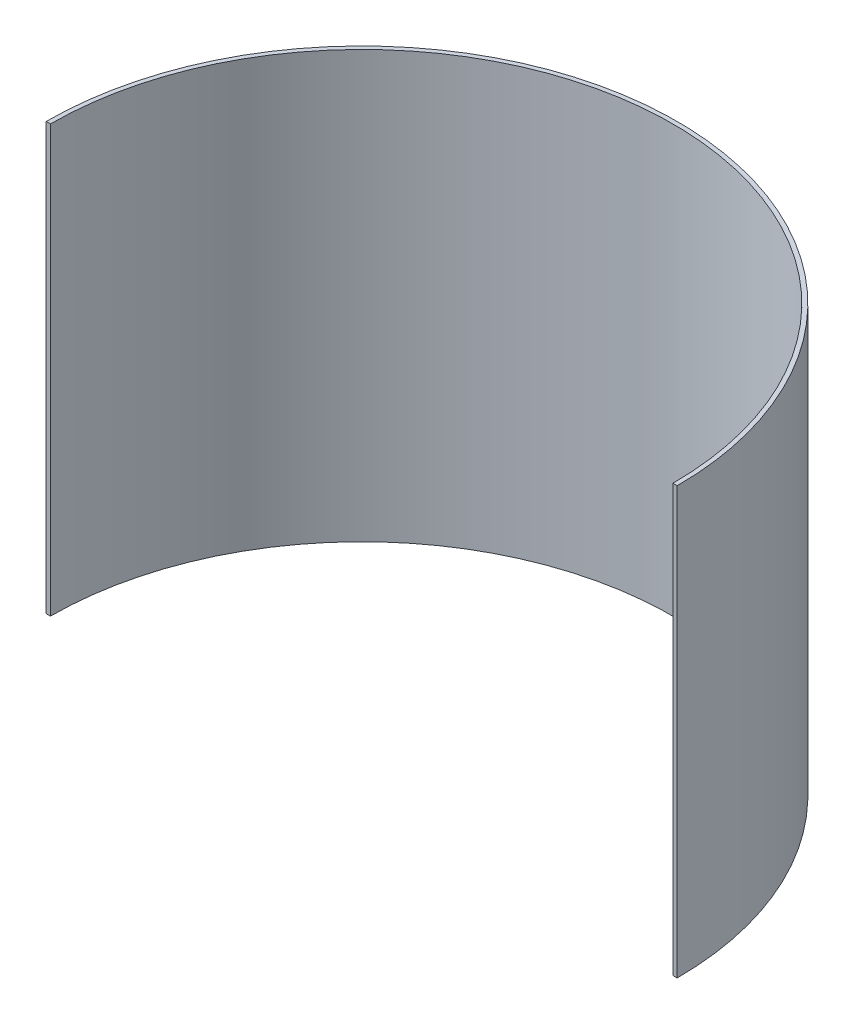
from build123d import *

# Parameters (mm, degrees)
SKETCH1_R           = 37
SKETCH1_R_2         = 36.5
BOSS_EXTRUDE1_DEPTH = 50
CUT_EXTRUDE2_DEPTH  = 51


with BuildPart() as part:
    # Sketch1 → Boss-Extrude1 (new body)
    with BuildSketch(Plane(origin=(0, 0, 0), x_dir=(1, 0, 0), z_dir=(0, 1, 0))):
        Circle(SKETCH1_R)
        Circle(SKETCH1_R_2, mode=Mode.SUBTRACT)
    extrude(amount=BOSS_EXTRUDE1_DEPTH)

    # Sketch2 → Cut-Extrude2 (cut, through all)
    with BuildSketch(Plane(origin=(0, 0, 0), x_dir=(1, 0, 0), z_dir=(0, 1, 0))):
        with BuildLine():
            Line((37, 0), (-37, 0))
            ThreePointArc((-37, 0), (0, -37), (37, 0))
        make_face()
    extrude(amount=CUT_EXTRUDE2_DEPTH, mode=Mode.SUBTRACT)


solid = part.part
